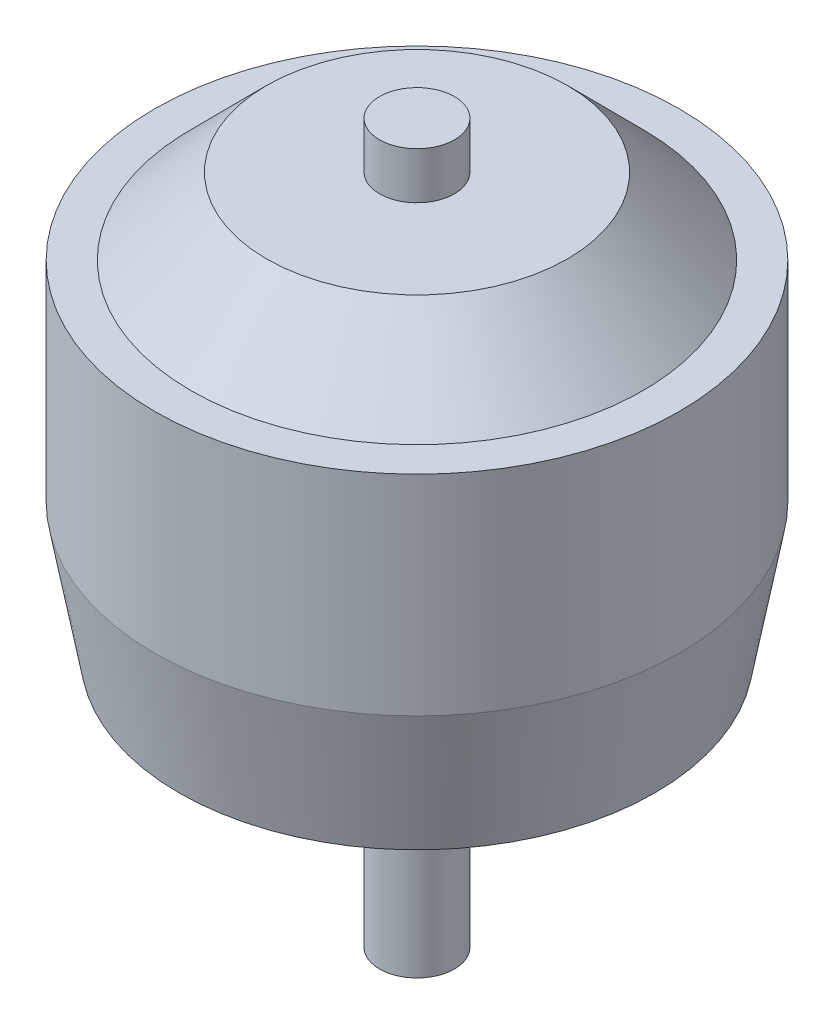
from build123d import *


with BuildPart() as part:
    # Sketch1 → Revolve1 (revolve)
    with BuildSketch(Plane(origin=(0, 0, 0), x_dir=(0, 0, -1), z_dir=(1, 0, 0))):
        Polygon((0, -16.8656), (-2.5, -16.8656), (-2.5, 0), (-15.875, 0), (-17.5006, 8.89), (-17.5006, 22.86), (-15.0876, 22.86), (-10.033, 27.94), (-2.5, 27.94), (-2.5, 31.0642), (0, 31.0642), align=None)
    revolve(axis=Axis((0, 0, 0), (0, -1, 0)))


solid = part.part
